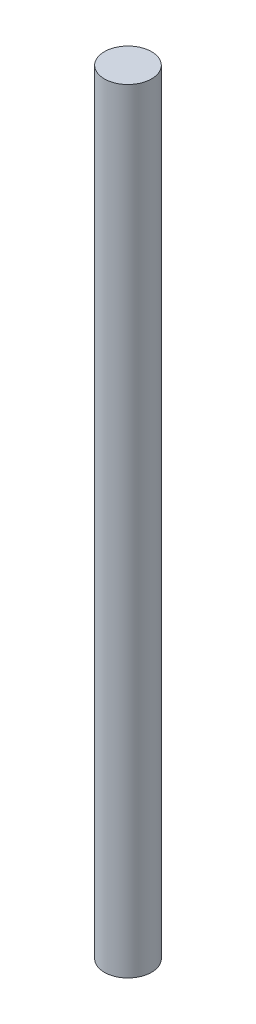
from build123d import *

# Parameters (mm, degrees)
SKETCH1_R           = 1.5875
BOSS_EXTRUDE1_DEPTH = 52.07


with BuildPart() as part:
    # Sketch1 → Boss-Extrude1 (new body)
    with BuildSketch(Plane(origin=(0, 0, 0), x_dir=(1, 0, 0), z_dir=(0, 1, 0))):
        Circle(SKETCH1_R)
    extrude(amount=BOSS_EXTRUDE1_DEPTH)


solid = part.part
